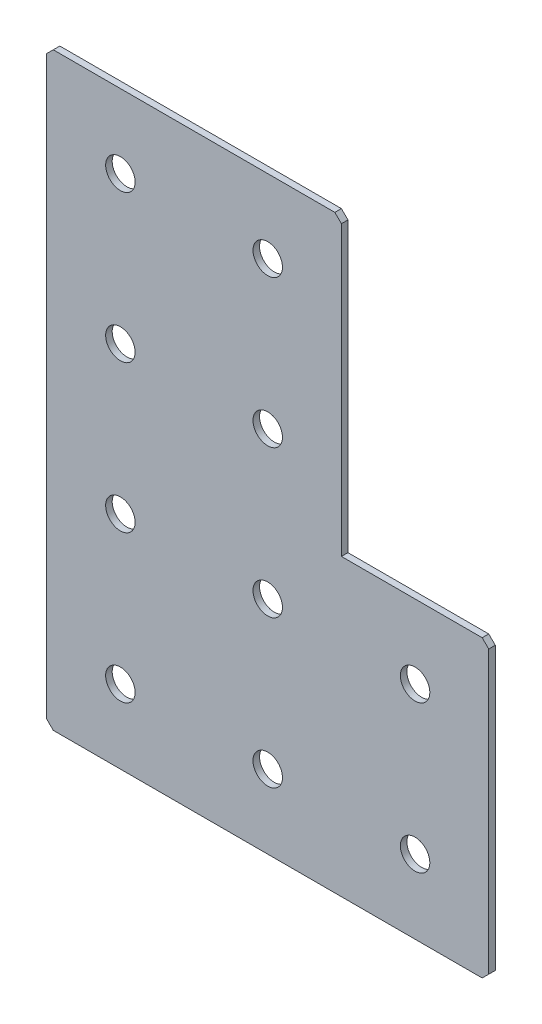
from build123d import *

# Parameters (mm, degrees)
EXTRUDE_1_DEPTH   = 2
HOLE_WIZARD_M81_D = 9
CHAMFER_1_SIZE    = 2


with BuildPart() as part:
    # Эскиз1 → Бобышка-Вытянуть1 (new body)
    with BuildSketch(Plane(origin=(0, 0, 0), x_dir=(1, 0, 0), z_dir=(0, 0, -1))):
        Polygon((0, 0), (0, 180), (135, 180), (135, 90), (90, 90), (90, 0), align=None)
    extrude(amount=EXTRUDE_1_DEPTH)

    # Отверстие с зазором M81 (through all)
    with Locations(Plane(origin=(0, 0, -2), x_dir=(1, 0, 0), z_dir=(0, 0, -1))):
        with Locations((22.5, 157.5), (22.5, 112.5), (22.5, 67.5), (22.5, 22.5), (67.5, 157.5), (67.5, 112.5), (67.5, 67.5), (67.5, 22.5), (112.5, 157.5), (112.5, 112.5)):
            Hole(HOLE_WIZARD_M81_D / 2)

    # Фаска1
    chamfer_1_edges = [part.edges().sort_by_distance(p)[0] for p in [
        (0, 0, -1),
        (0, -180, -1),
        (135, -180, -1),
        (135, -90, -1),
        (90, 0, -1),
    ]]
    chamfer(chamfer_1_edges, length=CHAMFER_1_SIZE)


solid = part.part
